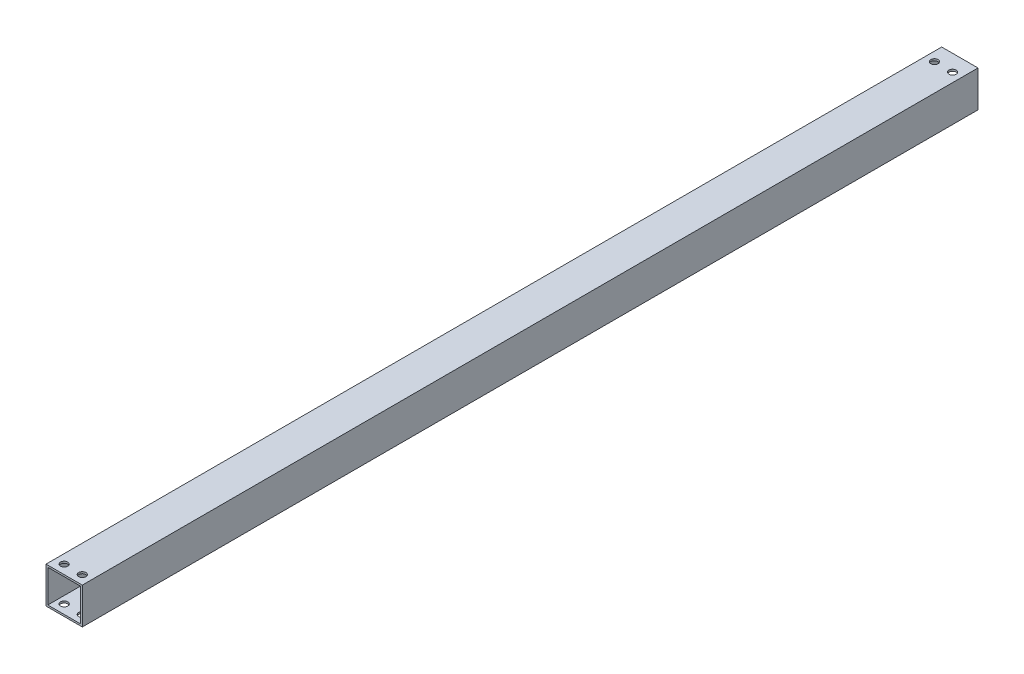
from build123d import *

# Parameters (mm, degrees)
SKETCH_1_W                = 20
SKETCH_1_H                = 20
SKETCH_1_W_2              = 18
SKETCH_1_H_2              = 18
EXTRUDE_1_DEPTH           = 493.33
SKETCH_5_R                = 2
CUT_EXTRUDE_12_DEPTH      = 20
CUT_EXTRUDE_13_DEPTH      = 146
CUT_EXTRUDE_13_DEPTH_BACK = 84
SKETCH_6_R                = 2


with BuildPart() as part:
    # 草图1 → 凸台-拉伸1 (new body)
    with BuildSketch(Plane.XY):
        Rectangle(SKETCH_1_W, SKETCH_1_H)
        Rectangle(SKETCH_1_W_2, SKETCH_1_H_2, mode=Mode.SUBTRACT)
    extrude(amount=EXTRUDE_1_DEPTH)

    # 草图5 → 切除-拉伸12 (cut)
    with BuildSketch(Plane.XZ.offset(-9)):
        with Locations((-5, 9)):
            Circle(SKETCH_5_R)
        with Locations((5, 9)):
            Circle(SKETCH_5_R)
    extrude(amount=-CUT_EXTRUDE_12_DEPTH, mode=Mode.SUBTRACT)

    # 草图6 → 切除-拉伸13 (cut, two sides: drawn at the far end of the back side and taken through both)
    with BuildSketch(Plane(origin=(0, -9, 0), x_dir=(1, 0, 0), z_dir=(0, 1, 0)).offset(-CUT_EXTRUDE_13_DEPTH_BACK)):
        with Locations((5, -9)):
            Circle(SKETCH_6_R)
        with Locations((-5, -9)):
            Circle(SKETCH_6_R)
        with Locations((293.56, -9)):
            Circle(SKETCH_6_R)
        with Locations((303.56, -9)):
            Circle(SKETCH_6_R)
        with Locations((15.394157217, -488.33)):
            Circle(SKETCH_6_R)
        with Locations((15.394157217, -478.33)):
            Circle(SKETCH_6_R)
        with Locations((-5, -488.33)):
            Circle(SKETCH_6_R)
        with Locations((5, -488.33)):
            Circle(SKETCH_6_R)
        with Locations((303.56, -488.33)):
            Circle(SKETCH_6_R)
        with Locations((293.56, -488.33)):
            Circle(SKETCH_6_R)
        with Locations((283.56, -488.33)):
            Circle(SKETCH_6_R)
        with Locations((283.56, -478.33)):
            Circle(SKETCH_6_R)
    extrude(amount=CUT_EXTRUDE_13_DEPTH + CUT_EXTRUDE_13_DEPTH_BACK, mode=Mode.SUBTRACT)


solid = part.part
